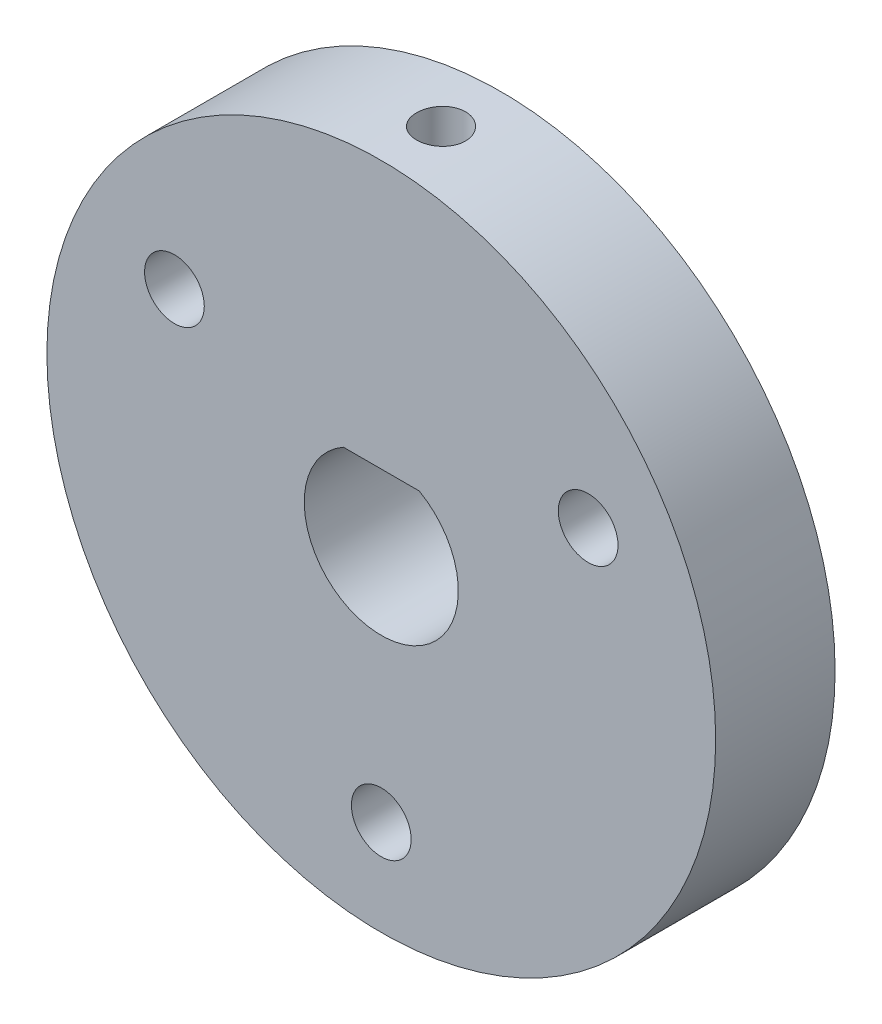
from build123d import *

# Parameters (mm, degrees)
SKETCH1_R              = 14
BOSS_EXTRUDE1_DEPTH    = 2.5
M2_5_CLEARANCE_HOLE2_D = 2.5
CIRPATTERN1_COUNT      = 3
SKETCH7_W              = 1.025
SKETCH7_H              = 11.192782739


with BuildPart() as part:
    # Sketch1 → Boss-Extrude1 (new body, symmetric)
    with BuildSketch(Plane.XY):
        Circle(SKETCH1_R)
        with BuildLine():
            Line((-1.5875, 2.807217261), (1.5875, 2.807217261))
            ThreePointArc((1.5875, 2.807217261), (0, -3.225), (-1.5875, 2.807217261))
        make_face(mode=Mode.SUBTRACT)
    extrude(amount=BOSS_EXTRUDE1_DEPTH, both=True)

    # M2.5 Clearance Hole2 (through all)
    with Locations(Plane.XY.offset(2.5)):
        with Locations((0, -10)):
            m2_5_clearance_hole2 = Hole(M2_5_CLEARANCE_HOLE2_D / 2)

    # CirPattern1: M2.5 Clearance Hole2 ×3 about axis
    cirpattern1_axis = Axis((0, 0, 0), (0, 0, 1))
    for i in range(1, CIRPATTERN1_COUNT):
        add(m2_5_clearance_hole2.rotate(cirpattern1_axis, i * 360 / CIRPATTERN1_COUNT), mode=Mode.SUBTRACT)

    # Sketch7 → M2.5x0.45 Tapped Hole1 (revolve, cut)
    with BuildSketch(Plane(origin=(0, 2.807217261, 0), x_dir=(0, 0, -1), z_dir=(1, 0, 0))):
        with Locations((0.5125, 5.59639137)):
            Rectangle(SKETCH7_W, SKETCH7_H)
    revolve(axis=Axis((0, -3.542782739, 0), (0, 1, 0)), mode=Mode.SUBTRACT)


solid = part.part
